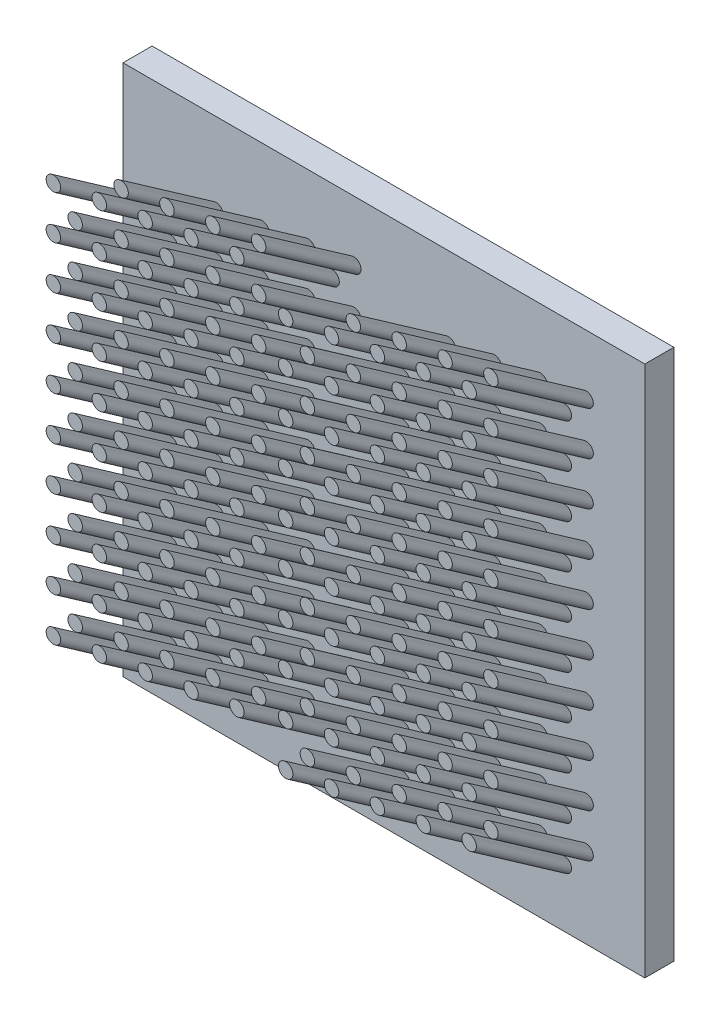
from build123d import *

# Parameters (mm, degrees)
SKETCH1_R       = 0.125
EXTRUDE1_DEPTH  = 2
LPATTERN2_COUNT = 2
LPATTERN2_PITCH = 4
EXTRUDE2_START  = -0.5
SKETCH5_W       = 8.986878449
SKETCH5_H       = 9.157970872
EXTRUDE2_DEPTH  = 0.5


with BuildPart() as part:
    # Sketch1 → Extrude1 (new body, along a direction that is not the sketch's normal)
    with BuildSketch(Plane.XY):
        with Locations((3.16060269, 0.500590288)):
            Circle(SKETCH1_R)
        with Locations((3.16060269, 1.250590288)):
            Circle(SKETCH1_R)
        with Locations((3.16060269, 2.000590288)):
            Circle(SKETCH1_R)
        with Locations((3.16060269, 2.750590288)):
            Circle(SKETCH1_R)
        with Locations((3.16060269, 3.500590288)):
            Circle(SKETCH1_R)
        with Locations((3.16060269, 4.250590288)):
            Circle(SKETCH1_R)
        with Locations((3.16060269, 5.000590288)):
            Circle(SKETCH1_R)
        with Locations((3.16060269, 5.750590288)):
            Circle(SKETCH1_R)
        with Locations((3.16060269, 6.500590288)):
            Circle(SKETCH1_R)
        with Locations((3.16060269, 7.250590288)):
            Circle(SKETCH1_R)
        with Locations((3.535546061, 0.875533659)):
            Circle(SKETCH1_R)
        with Locations((3.535546061, 1.625533659)):
            Circle(SKETCH1_R)
        with Locations((3.535546061, 2.375533659)):
            Circle(SKETCH1_R)
        with Locations((3.535546061, 3.125533659)):
            Circle(SKETCH1_R)
        with Locations((3.535546061, 3.875533659)):
            Circle(SKETCH1_R)
        with Locations((3.535546061, 4.625533659)):
            Circle(SKETCH1_R)
        with Locations((3.535546061, 5.375533659)):
            Circle(SKETCH1_R)
        with Locations((3.535546061, 6.125533659)):
            Circle(SKETCH1_R)
        with Locations((3.535546061, 6.875533659)):
            Circle(SKETCH1_R)
        with Locations((3.950753362, 0.62573786)):
            Circle(SKETCH1_R)
        with Locations((3.950753362, 1.37573786)):
            Circle(SKETCH1_R)
        with Locations((3.950753362, 2.12573786)):
            Circle(SKETCH1_R)
        with Locations((3.950753362, 2.87573786)):
            Circle(SKETCH1_R)
        with Locations((3.950753362, 3.62573786)):
            Circle(SKETCH1_R)
        with Locations((3.950753362, 4.37573786)):
            Circle(SKETCH1_R)
        with Locations((3.950753362, 5.12573786)):
            Circle(SKETCH1_R)
        with Locations((3.950753362, 5.87573786)):
            Circle(SKETCH1_R)
        with Locations((3.950753362, 6.62573786)):
            Circle(SKETCH1_R)
        with Locations((3.950753362, 7.37573786)):
            Circle(SKETCH1_R)
        with Locations((4.325696733, 1.000681231)):
            Circle(SKETCH1_R)
        with Locations((4.325696733, 1.750681231)):
            Circle(SKETCH1_R)
        with Locations((4.325696733, 2.500681231)):
            Circle(SKETCH1_R)
        with Locations((4.325696733, 3.250681231)):
            Circle(SKETCH1_R)
        with Locations((4.325696733, 4.000681231)):
            Circle(SKETCH1_R)
        with Locations((4.325696733, 4.750681231)):
            Circle(SKETCH1_R)
        with Locations((4.325696733, 5.500681231)):
            Circle(SKETCH1_R)
        with Locations((4.325696733, 6.250681231)):
            Circle(SKETCH1_R)
        with Locations((4.325696733, 7.000681231)):
            Circle(SKETCH1_R)
        with Locations((4.325696733, 7.750681231)):
            Circle(SKETCH1_R)
        with Locations((4.740904035, 0.750885432)):
            Circle(SKETCH1_R)
        with Locations((4.740904035, 1.500885432)):
            Circle(SKETCH1_R)
        with Locations((4.740904035, 2.250885432)):
            Circle(SKETCH1_R)
        with Locations((4.740904035, 3.000885432)):
            Circle(SKETCH1_R)
        with Locations((4.740904035, 3.750885432)):
            Circle(SKETCH1_R)
        with Locations((4.740904035, 4.500885432)):
            Circle(SKETCH1_R)
        with Locations((4.740904035, 5.250885432)):
            Circle(SKETCH1_R)
        with Locations((4.740904035, 6.000885432)):
            Circle(SKETCH1_R)
        with Locations((4.740904035, 6.750885432)):
            Circle(SKETCH1_R)
        with Locations((4.740904035, 7.500885432)):
            Circle(SKETCH1_R)
        with Locations((5.115847406, 1.125828803)):
            Circle(SKETCH1_R)
        with Locations((5.115847406, 1.875828803)):
            Circle(SKETCH1_R)
        with Locations((5.115847406, 2.625828803)):
            Circle(SKETCH1_R)
        with Locations((5.115847406, 3.375828803)):
            Circle(SKETCH1_R)
        with Locations((5.115847406, 4.125828803)):
            Circle(SKETCH1_R)
        with Locations((5.115847406, 4.875828803)):
            Circle(SKETCH1_R)
        with Locations((5.115847406, 5.625828803)):
            Circle(SKETCH1_R)
        with Locations((5.115847406, 6.375828803)):
            Circle(SKETCH1_R)
        with Locations((5.115847406, 7.125828803)):
            Circle(SKETCH1_R)
        with Locations((5.115847406, 7.875828803)):
            Circle(SKETCH1_R)
        with Locations((5.531054707, 0.876033004)):
            Circle(SKETCH1_R)
        with Locations((5.531054707, 1.626033004)):
            Circle(SKETCH1_R)
        with Locations((5.531054707, 2.376033004)):
            Circle(SKETCH1_R)
        with Locations((5.531054707, 3.126033004)):
            Circle(SKETCH1_R)
        with Locations((5.531054707, 3.876033004)):
            Circle(SKETCH1_R)
        with Locations((5.531054707, 4.626033004)):
            Circle(SKETCH1_R)
        with Locations((5.531054707, 5.376033004)):
            Circle(SKETCH1_R)
        with Locations((5.531054707, 6.126033004)):
            Circle(SKETCH1_R)
        with Locations((5.531054707, 6.876033004)):
            Circle(SKETCH1_R)
        with Locations((5.531054707, 7.626033004)):
            Circle(SKETCH1_R)
        with Locations((5.905998078, 1.250976375)):
            Circle(SKETCH1_R)
        with Locations((5.905998078, 2.000976375)):
            Circle(SKETCH1_R)
        with Locations((5.905998078, 2.750976375)):
            Circle(SKETCH1_R)
        with Locations((5.905998078, 3.500976375)):
            Circle(SKETCH1_R)
        with Locations((5.905998078, 4.250976375)):
            Circle(SKETCH1_R)
        with Locations((5.905998078, 5.000976375)):
            Circle(SKETCH1_R)
        with Locations((5.905998078, 5.750976375)):
            Circle(SKETCH1_R)
        with Locations((5.905998078, 6.500976375)):
            Circle(SKETCH1_R)
        with Locations((5.905998078, 7.250976375)):
            Circle(SKETCH1_R)
        with Locations((5.905998078, 8.000976375)):
            Circle(SKETCH1_R)
        with Locations((6.32120538, 1.001180576)):
            Circle(SKETCH1_R)
        with Locations((6.32120538, 1.751180576)):
            Circle(SKETCH1_R)
        with Locations((6.32120538, 2.501180576)):
            Circle(SKETCH1_R)
        with Locations((6.32120538, 3.251180576)):
            Circle(SKETCH1_R)
        with Locations((6.32120538, 4.001180576)):
            Circle(SKETCH1_R)
        with Locations((6.32120538, 4.751180576)):
            Circle(SKETCH1_R)
        with Locations((6.32120538, 5.501180576)):
            Circle(SKETCH1_R)
        with Locations((6.32120538, 6.251180576)):
            Circle(SKETCH1_R)
        with Locations((6.32120538, 7.001180576)):
            Circle(SKETCH1_R)
        with Locations((6.32120538, 7.751180576)):
            Circle(SKETCH1_R)
        with Locations((6.696148751, 1.376123947)):
            Circle(SKETCH1_R)
        with Locations((6.696148751, 2.126123947)):
            Circle(SKETCH1_R)
        with Locations((6.696148751, 2.876123947)):
            Circle(SKETCH1_R)
        with Locations((6.696148751, 3.626123947)):
            Circle(SKETCH1_R)
        with Locations((6.696148751, 4.376123947)):
            Circle(SKETCH1_R)
        with Locations((6.696148751, 5.126123947)):
            Circle(SKETCH1_R)
        with Locations((6.696148751, 5.876123947)):
            Circle(SKETCH1_R)
        with Locations((6.696148751, 6.626123947)):
            Circle(SKETCH1_R)
        with Locations((6.696148751, 7.376123947)):
            Circle(SKETCH1_R)
        with Locations((6.696148751, 8.126123947)):
            Circle(SKETCH1_R)
    extrude1 = extrude(amount=EXTRUDE1_DEPTH, dir=(0, 0.573576436, 0.819152044))



with BuildPart() as lpattern2_1:
    # LPattern2: Extrude1 ×2
    with Locations(*[(-i * LPATTERN2_PITCH, 0, 0) for i in range(1, LPATTERN2_COUNT)]):
        add(extrude1)


with BuildPart() as part_1:
    add(part.part)

    add(lpattern2_1.part)  # Extrude2 merges LPattern2_1
    # Sketch5 → Extrude2 (add)
    with BuildSketch(Plane.XY.offset(EXTRUDE2_START)):
        with Locations((3.214661322, 4.578985436)):
            Rectangle(SKETCH5_W, SKETCH5_H)
    extrude(amount=EXTRUDE2_DEPTH)


solid = part_1.part
